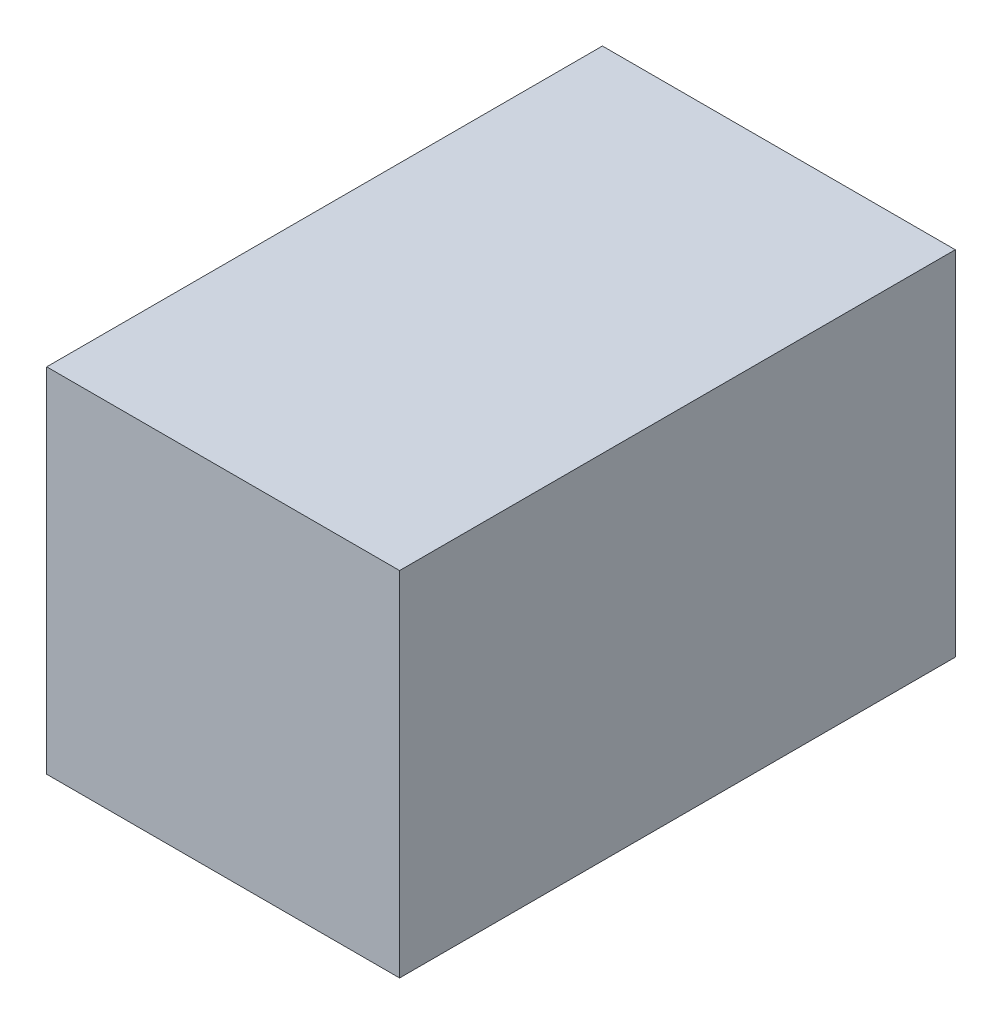
from build123d import *

# Parameters (mm, degrees)
BOSS_EXTRUDE1_DEPTH      = 35
BOSS_EXTRUDE1_DEPTH_BACK = 35
SKETCH1_W                = 44.45
SKETCH1_H                = 44.45


with BuildPart() as part:
    # Sketch1 → Boss-Extrude1 (new, two sides: drawn at the far end of the back side and taken through both)
    with BuildSketch(Plane.XY.offset(-BOSS_EXTRUDE1_DEPTH_BACK)):
        Rectangle(SKETCH1_W, SKETCH1_H)
    extrude(amount=BOSS_EXTRUDE1_DEPTH + BOSS_EXTRUDE1_DEPTH_BACK)


solid = part.part
